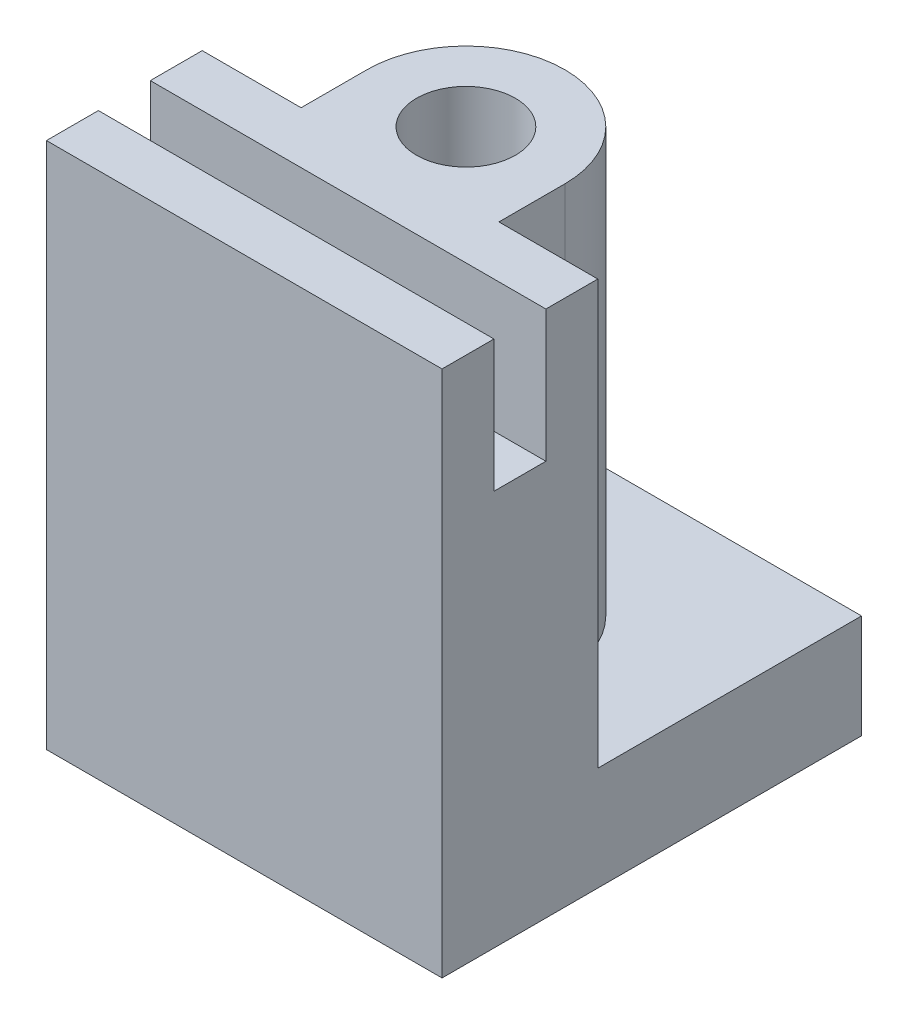
from build123d import *

# Parameters (mm, degrees)
BOSS_EXTRUDE1_DEPTH = 38.1
BOSS_EXTRUDE2_REACH = 52.8
SKETCH2_R           = 4.7625


with BuildPart() as part:
    # Sketch1 → Boss-Extrude1 (new body)
    with BuildSketch(Plane(origin=(0, 0, 0), x_dir=(0, 0, -1), z_dir=(1, 0, 0))):
        Polygon((0, 0), (40.4, 0), (40.4, 10), (15, 10), (15, 50.8), (10, 50.8), (10, 38.1), (5, 38.1), (5, 50.8), (0, 50.8), align=None)
    extrude(amount=BOSS_EXTRUDE1_DEPTH)

    # Sketch2 → Boss-Extrude2 (add, up to next)
    with BuildSketch(Plane(origin=(0, 50.8, 0), x_dir=(1, 0, 0), z_dir=(0, 1, 0)), mode=Mode.PRIVATE) as boss_extrude2_sk1:
        with BuildLine():
            Line((9.525, 21.35), (9.525, 15))
            Line((9.525, 15), (28.575, 15))
            Line((28.575, 15), (28.575, 21.35))
            ThreePointArc((28.575, 21.35), (19.05, 30.875), (9.525, 21.35))
        make_face()
        with Locations((19.05, 21.35)):
            Circle(SKETCH2_R, mode=Mode.SUBTRACT)
    boss_extrude2_tool1 = extrude(boss_extrude2_sk1.sketch, amount=-BOSS_EXTRUDE2_REACH, mode=Mode.PRIVATE) - part.part
    add(boss_extrude2_tool1.solids().sort_by_distance((9.772975, 50.8, -18.175))[0])


solid = part.part
